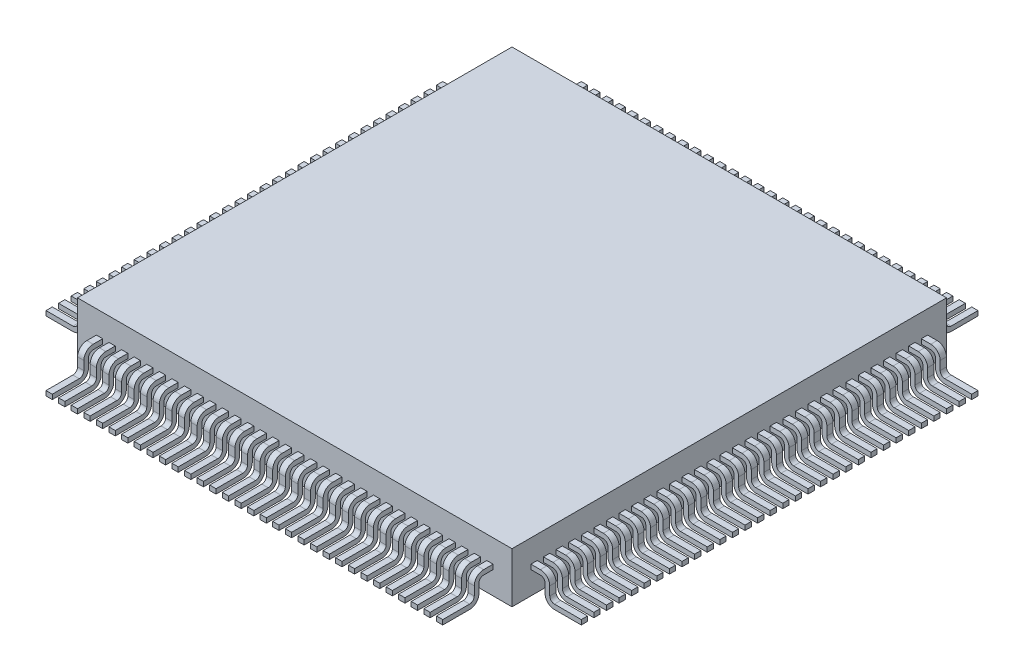
from build123d import *

# Parameters (mm, degrees)
SKETCH1_W           = 13.8
SKETCH1_H           = 13.8
BOSS_EXTRUDE1_DEPTH = 1.6
SKETCH2_W           = 0.2
SKETCH2_H           = 0.15
CIRPATTERN1_COUNT   = 4


with BuildPart() as part:
    # Sketch1 → Boss-Extrude1 (new body)
    with BuildSketch(Plane(origin=(0, 0, 0), x_dir=(1, 0, 0), z_dir=(0, 1, 0))):
        with Locations((6.9, 6.9)):
            Rectangle(SKETCH1_W, SKETCH1_H)
    extrude(amount=BOSS_EXTRUDE1_DEPTH)

    # Sweep1: sweep along a path in Sketch3
    with BuildLine(Plane(origin=(0, 0, 0), x_dir=(0, 0, -1), z_dir=(1, 0, 0))) as sweep1_path:
        Line((0, 0.8), (-0.30065215, 0.8))
        ThreePointArc((-0.30065215, 0.8), (-0.458340314, 0.734683424), (-0.523656891, 0.576995259))
        Line((-0.523656891, 0.576995259), (-0.523656891, 0.298004741))
        ThreePointArc((-0.523656891, 0.298004741), (-0.588973467, 0.140316576), (-0.746661631, 0.075))
        Line((-0.746661631, 0.075), (-1.6, 0.075))
    # Sketch2 → Sweep1 (sweep)
    with BuildSketch(Plane.XY):
        with Locations((0.7, 0.8)):
            Rectangle(SKETCH2_W, SKETCH2_H)
        with Locations((1.1, 0.8)):
            Rectangle(SKETCH2_W, SKETCH2_H)
        with Locations((1.5, 0.8)):
            Rectangle(SKETCH2_W, SKETCH2_H)
        with Locations((1.9, 0.8)):
            Rectangle(SKETCH2_W, SKETCH2_H)
        with Locations((2.3, 0.8)):
            Rectangle(SKETCH2_W, SKETCH2_H)
        with Locations((2.7, 0.8)):
            Rectangle(SKETCH2_W, SKETCH2_H)
        with Locations((3.1, 0.8)):
            Rectangle(SKETCH2_W, SKETCH2_H)
        with Locations((3.5, 0.8)):
            Rectangle(SKETCH2_W, SKETCH2_H)
        with Locations((3.9, 0.8)):
            Rectangle(SKETCH2_W, SKETCH2_H)
        with Locations((4.3, 0.8)):
            Rectangle(SKETCH2_W, SKETCH2_H)
        with Locations((4.7, 0.8)):
            Rectangle(SKETCH2_W, SKETCH2_H)
        with Locations((5.1, 0.8)):
            Rectangle(SKETCH2_W, SKETCH2_H)
        with Locations((5.5, 0.8)):
            Rectangle(SKETCH2_W, SKETCH2_H)
        with Locations((5.9, 0.8)):
            Rectangle(SKETCH2_W, SKETCH2_H)
        with Locations((6.3, 0.8)):
            Rectangle(SKETCH2_W, SKETCH2_H)
        with Locations((6.7, 0.8)):
            Rectangle(SKETCH2_W, SKETCH2_H)
        with Locations((7.1, 0.8)):
            Rectangle(SKETCH2_W, SKETCH2_H)
        with Locations((7.5, 0.8)):
            Rectangle(SKETCH2_W, SKETCH2_H)
        with Locations((7.9, 0.8)):
            Rectangle(SKETCH2_W, SKETCH2_H)
        with Locations((8.3, 0.8)):
            Rectangle(SKETCH2_W, SKETCH2_H)
        with Locations((8.7, 0.8)):
            Rectangle(SKETCH2_W, SKETCH2_H)
        with Locations((9.1, 0.8)):
            Rectangle(SKETCH2_W, SKETCH2_H)
        with Locations((9.5, 0.8)):
            Rectangle(SKETCH2_W, SKETCH2_H)
        with Locations((9.9, 0.8)):
            Rectangle(SKETCH2_W, SKETCH2_H)
        with Locations((10.3, 0.8)):
            Rectangle(SKETCH2_W, SKETCH2_H)
        with Locations((10.7, 0.8)):
            Rectangle(SKETCH2_W, SKETCH2_H)
        with Locations((11.1, 0.8)):
            Rectangle(SKETCH2_W, SKETCH2_H)
        with Locations((11.5, 0.8)):
            Rectangle(SKETCH2_W, SKETCH2_H)
        with Locations((11.9, 0.8)):
            Rectangle(SKETCH2_W, SKETCH2_H)
        with Locations((12.3, 0.8)):
            Rectangle(SKETCH2_W, SKETCH2_H)
        with Locations((12.7, 0.8)):
            Rectangle(SKETCH2_W, SKETCH2_H)
        with Locations((13.1, 0.8)):
            Rectangle(SKETCH2_W, SKETCH2_H)
    sweep1 = sweep(path=sweep1_path.line)

    # CirPattern1: Sweep1 ×4 about axis
    cirpattern1_axis = Axis((6.9, 2.58598966, -6.9), (0, -1, 0))
    for i in range(1, CIRPATTERN1_COUNT):
        add(sweep1.rotate(cirpattern1_axis, i * 360 / CIRPATTERN1_COUNT))


solid = part.part
